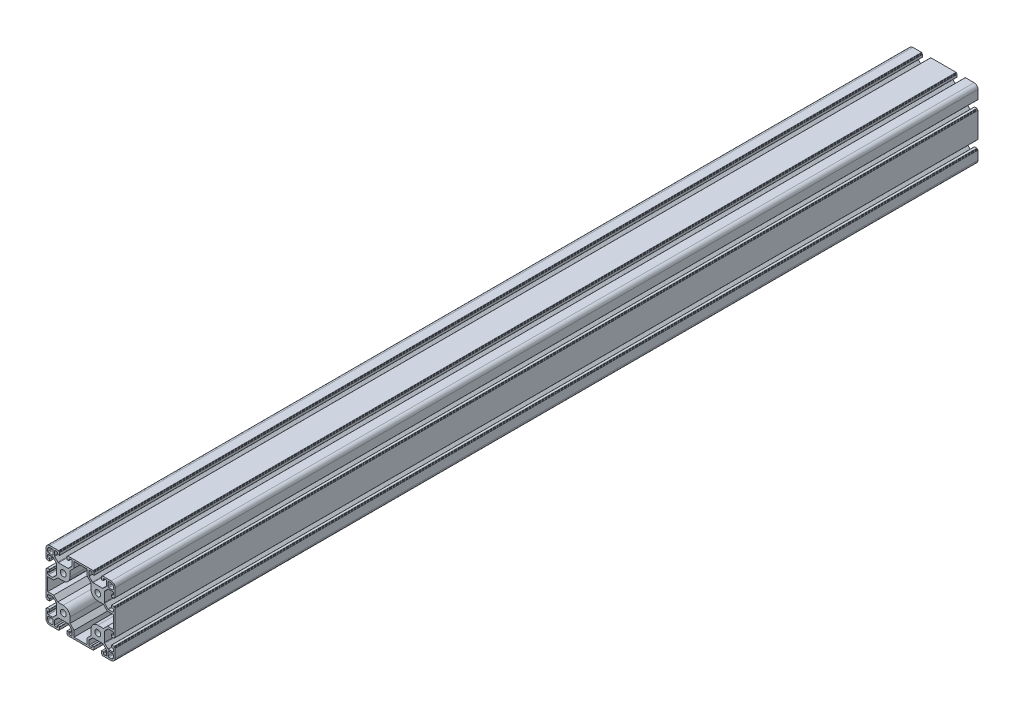
from build123d import *

# Parameters (mm, degrees)
SKETCH_1_R      = 3.4
EXTRUDE_1_DEPTH = 1000


with BuildPart() as part:
    # Эскиз1 → Бобышка-Вытянуть1 (new body)
    with BuildSketch(Plane.XY):
        with BuildLine():
            Line((-20, 10.25), (-20, 15.5))
            ThreePointArc((-20, 15.5), (-18.681980515, 18.681980515), (-15.5, 20))
            Line((-15.5, 20), (-10.25, 20))
            Line((-10.25, 20), (-5.4, 20))
            ThreePointArc((-5.4, 20), (-5.187867966, 19.912132034), (-5.1, 19.7))
            Line((-5.1, 19.7), (-5.1, 19.3))
            ThreePointArc((-5.1, 19.3), (-5.012132034, 19.087867966), (-4.8, 19))
            Line((-4.8, 19), (-4.4, 19))
            ThreePointArc((-4.4, 19), (-4.187867966, 18.912132034), (-4.1, 18.7))
            Line((-4.1, 18.7), (-4.1, 16))
            ThreePointArc((-4.1, 16), (-4.187867966, 15.787867966), (-4.4, 15.7))
            Line((-4.4, 15.7), (-6.3, 15.7))
            ThreePointArc((-6.3, 15.7), (-6.512132034, 15.787867966), (-6.6, 16))
            Line((-6.6, 16), (-6.6, 17.2))
            ThreePointArc((-6.6, 17.2), (-6.892893219, 17.907106781), (-7.6, 18.2))
            Line((-7.6, 18.2), (-9.25, 18.2))
            ThreePointArc((-9.25, 18.2), (-9.957106781, 17.907106781), (-10.25, 17.2))
            Line((-10.25, 17.2), (-10.25, 12.464213562))
            ThreePointArc((-10.25, 12.464213562), (-10.173879533, 12.08153013), (-9.957106781, 11.757106781))
            Line((-9.957106781, 11.757106781), (-6.192893219, 7.992893219))
            ThreePointArc((-6.192893219, 7.992893219), (-5.86846987, 7.776120467), (-5.485786438, 7.7))
            Line((-5.485786438, 7.7), (5.485786438, 7.7))
            ThreePointArc((5.485786438, 7.7), (5.86846987, 7.776120467), (6.192893219, 7.992893219))
            Line((6.192893219, 7.992893219), (9.957106781, 11.757106781))
            ThreePointArc((9.957106781, 11.757106781), (10.173879533, 12.08153013), (10.25, 12.464213562))
            Line((10.25, 12.464213562), (10.25, 17.2))
            ThreePointArc((10.25, 17.2), (9.957106781, 17.907106781), (9.25, 18.2))
            Line((9.25, 18.2), (7.6, 18.2))
            ThreePointArc((7.6, 18.2), (6.892893219, 17.907106781), (6.6, 17.2))
            Line((6.6, 17.2), (6.6, 16))
            ThreePointArc((6.6, 16), (6.512132034, 15.787867966), (6.3, 15.7))
            Line((6.3, 15.7), (4.4, 15.7))
            ThreePointArc((4.4, 15.7), (4.187867966, 15.787867966), (4.1, 16))
            Line((4.1, 16), (4.1, 18.7))
            ThreePointArc((4.1, 18.7), (4.187867966, 18.912132034), (4.4, 19))
            Line((4.4, 19), (4.8, 19))
            ThreePointArc((4.8, 19), (5.012132034, 19.087867966), (5.1, 19.3))
            Line((5.1, 19.3), (5.1, 19.7))
            ThreePointArc((5.1, 19.7), (5.187867966, 19.912132034), (5.4, 20))
            Line((5.4, 20), (10.25, 20))
            Line((10.25, 20), (29.75, 20))
            Line((29.75, 20), (34.6, 20))
            ThreePointArc((34.6, 20), (34.812132034, 19.912132034), (34.9, 19.7))
            Line((34.9, 19.7), (34.9, 19.3))
            ThreePointArc((34.9, 19.3), (34.987867966, 19.087867966), (35.2, 19))
            Line((35.2, 19), (35.6, 19))
            ThreePointArc((35.6, 19), (35.812132034, 18.912132034), (35.9, 18.7))
            Line((35.9, 18.7), (35.9, 16))
            ThreePointArc((35.9, 16), (35.812132034, 15.787867966), (35.6, 15.7))
            Line((35.6, 15.7), (33.7, 15.7))
            ThreePointArc((33.7, 15.7), (33.487867966, 15.787867966), (33.4, 16))
            Line((33.4, 16), (33.4, 17.2))
            ThreePointArc((33.4, 17.2), (33.107106781, 17.907106781), (32.4, 18.2))
            Line((32.4, 18.2), (30.75, 18.2))
            ThreePointArc((30.75, 18.2), (30.042893219, 17.907106781), (29.75, 17.2))
            Line((29.75, 17.2), (29.75, 12.464213562))
            ThreePointArc((29.75, 12.464213562), (29.826120467, 12.08153013), (30.042893219, 11.757106781))
            Line((30.042893219, 11.757106781), (33.807106781, 7.992893219))
            ThreePointArc((33.807106781, 7.992893219), (34.13153013, 7.776120467), (34.514213562, 7.7))
            Line((34.514213562, 7.7), (45.485786438, 7.7))
            ThreePointArc((45.485786438, 7.7), (45.86846987, 7.776120467), (46.192893219, 7.992893219))
            Line((46.192893219, 7.992893219), (49.957106781, 11.757106781))
            ThreePointArc((49.957106781, 11.757106781), (50.173879533, 12.08153013), (50.25, 12.464213562))
            Line((50.25, 12.464213562), (50.25, 17.2))
            ThreePointArc((50.25, 17.2), (49.957106781, 17.907106781), (49.25, 18.2))
            Line((49.25, 18.2), (47.6, 18.2))
            ThreePointArc((47.6, 18.2), (46.892893219, 17.907106781), (46.6, 17.2))
            Line((46.6, 17.2), (46.6, 16))
            ThreePointArc((46.6, 16), (46.512132034, 15.787867966), (46.3, 15.7))
            Line((46.3, 15.7), (44.4, 15.7))
            ThreePointArc((44.4, 15.7), (44.187867966, 15.787867966), (44.1, 16))
            Line((44.1, 16), (44.1, 18.7))
            ThreePointArc((44.1, 18.7), (44.187867966, 18.912132034), (44.4, 19))
            Line((44.4, 19), (44.8, 19))
            ThreePointArc((44.8, 19), (45.012132034, 19.087867966), (45.1, 19.3))
            Line((45.1, 19.3), (45.1, 19.7))
            ThreePointArc((45.1, 19.7), (45.187867966, 19.912132034), (45.4, 20))
            Line((45.4, 20), (50.25, 20))
            Line((50.25, 20), (55.5, 20))
            ThreePointArc((55.5, 20), (58.681980515, 18.681980515), (60, 15.5))
            Line((60, 15.5), (60, 10.25))
            Line((60, 10.25), (60, 5.4))
            ThreePointArc((60, 5.4), (59.912132034, 5.187867966), (59.7, 5.1))
            Line((59.7, 5.1), (59.3, 5.1))
            ThreePointArc((59.3, 5.1), (59.087867966, 5.012132034), (59, 4.8))
            Line((59, 4.8), (59, 4.4))
            ThreePointArc((59, 4.4), (58.912132034, 4.187867966), (58.7, 4.1))
            Line((58.7, 4.1), (56, 4.1))
            ThreePointArc((56, 4.1), (55.787867966, 4.187867966), (55.7, 4.4))
            Line((55.7, 4.4), (55.7, 6.3))
            ThreePointArc((55.7, 6.3), (55.787867966, 6.512132034), (56, 6.6))
            Line((56, 6.6), (57.2, 6.6))
            ThreePointArc((57.2, 6.6), (57.907106781, 6.892893219), (58.2, 7.6))
            Line((58.2, 7.6), (58.2, 9.25))
            ThreePointArc((58.2, 9.25), (57.907106781, 9.957106781), (57.2, 10.25))
            Line((57.2, 10.25), (52.464213562, 10.25))
            ThreePointArc((52.464213562, 10.25), (52.08153013, 10.173879533), (51.757106781, 9.957106781))
            Line((51.757106781, 9.957106781), (47.992893219, 6.192893219))
            ThreePointArc((47.992893219, 6.192893219), (47.776120467, 5.86846987), (47.7, 5.485786438))
            Line((47.7, 5.485786438), (47.7, -5.485786438))
            ThreePointArc((47.7, -5.485786438), (47.776120467, -5.86846987), (47.992893219, -6.192893219))
            Line((47.992893219, -6.192893219), (51.757106781, -9.957106781))
            ThreePointArc((51.757106781, -9.957106781), (52.08153013, -10.173879533), (52.464213562, -10.25))
            Line((52.464213562, -10.25), (57.2, -10.25))
            ThreePointArc((57.2, -10.25), (57.907106781, -9.957106781), (58.2, -9.25))
            Line((58.2, -9.25), (58.2, -7.6))
            ThreePointArc((58.2, -7.6), (57.907106781, -6.892893219), (57.2, -6.6))
            Line((57.2, -6.6), (56, -6.6))
            ThreePointArc((56, -6.6), (55.787867966, -6.512132034), (55.7, -6.3))
            Line((55.7, -6.3), (55.7, -4.4))
            ThreePointArc((55.7, -4.4), (55.787867966, -4.187867966), (56, -4.1))
            Line((56, -4.1), (58.7, -4.1))
            ThreePointArc((58.7, -4.1), (58.912132034, -4.187867966), (59, -4.4))
            Line((59, -4.4), (59, -4.8))
            ThreePointArc((59, -4.8), (59.087867966, -5.012132034), (59.3, -5.1))
            Line((59.3, -5.1), (59.7, -5.1))
            ThreePointArc((59.7, -5.1), (59.912132034, -5.187867966), (60, -5.4))
            Line((60, -5.4), (60, -10.25))
            Line((60, -10.25), (60, -29.75))
            Line((60, -29.75), (60, -34.6))
            ThreePointArc((60, -34.6), (59.912132034, -34.812132034), (59.7, -34.9))
            Line((59.7, -34.9), (59.3, -34.9))
            ThreePointArc((59.3, -34.9), (59.087867966, -34.987867966), (59, -35.2))
            Line((59, -35.2), (59, -35.6))
            ThreePointArc((59, -35.6), (58.912132034, -35.812132034), (58.7, -35.9))
            Line((58.7, -35.9), (56, -35.9))
            ThreePointArc((56, -35.9), (55.787867966, -35.812132034), (55.7, -35.6))
            Line((55.7, -35.6), (55.7, -33.7))
            ThreePointArc((55.7, -33.7), (55.787867966, -33.487867966), (56, -33.4))
            Line((56, -33.4), (57.2, -33.4))
            ThreePointArc((57.2, -33.4), (57.907106781, -33.107106781), (58.2, -32.4))
            Line((58.2, -32.4), (58.2, -30.75))
            ThreePointArc((58.2, -30.75), (57.907106781, -30.042893219), (57.2, -29.75))
            Line((57.2, -29.75), (52.464213562, -29.75))
            ThreePointArc((52.464213562, -29.75), (52.08153013, -29.826120467), (51.757106781, -30.042893219))
            Line((51.757106781, -30.042893219), (47.992893219, -33.807106781))
            ThreePointArc((47.992893219, -33.807106781), (47.776120467, -34.13153013), (47.7, -34.514213562))
            Line((47.7, -34.514213562), (47.7, -45.485786438))
            ThreePointArc((47.7, -45.485786438), (47.776120467, -45.86846987), (47.992893219, -46.192893219))
            Line((47.992893219, -46.192893219), (51.757106781, -49.957106781))
            ThreePointArc((51.757106781, -49.957106781), (52.08153013, -50.173879533), (52.464213562, -50.25))
            Line((52.464213562, -50.25), (57.2, -50.25))
            ThreePointArc((57.2, -50.25), (57.907106781, -49.957106781), (58.2, -49.25))
            Line((58.2, -49.25), (58.2, -47.6))
            ThreePointArc((58.2, -47.6), (57.907106781, -46.892893219), (57.2, -46.6))
            Line((57.2, -46.6), (56, -46.6))
            ThreePointArc((56, -46.6), (55.787867966, -46.512132034), (55.7, -46.3))
            Line((55.7, -46.3), (55.7, -44.4))
            ThreePointArc((55.7, -44.4), (55.787867966, -44.187867966), (56, -44.1))
            Line((56, -44.1), (58.7, -44.1))
            ThreePointArc((58.7, -44.1), (58.912132034, -44.187867966), (59, -44.4))
            Line((59, -44.4), (59, -44.8))
            ThreePointArc((59, -44.8), (59.087867966, -45.012132034), (59.3, -45.1))
            Line((59.3, -45.1), (59.7, -45.1))
            ThreePointArc((59.7, -45.1), (59.912132034, -45.187867966), (60, -45.4))
            Line((60, -45.4), (60, -50.25))
            Line((60, -50.25), (60, -55.5))
            ThreePointArc((60, -55.5), (58.681980515, -58.681980515), (55.5, -60))
            Line((55.5, -60), (50.25, -60))
            Line((50.25, -60), (45.4, -60))
            ThreePointArc((45.4, -60), (45.187867966, -59.912132034), (45.1, -59.7))
            Line((45.1, -59.7), (45.1, -59.3))
            ThreePointArc((45.1, -59.3), (45.012132034, -59.087867966), (44.8, -59))
            Line((44.8, -59), (44.4, -59))
            ThreePointArc((44.4, -59), (44.187867966, -58.912132034), (44.1, -58.7))
            Line((44.1, -58.7), (44.1, -56))
            ThreePointArc((44.1, -56), (44.187867966, -55.787867966), (44.4, -55.7))
            Line((44.4, -55.7), (46.3, -55.7))
            ThreePointArc((46.3, -55.7), (46.512132034, -55.787867966), (46.6, -56))
            Line((46.6, -56), (46.6, -57.2))
            ThreePointArc((46.6, -57.2), (46.892893219, -57.907106781), (47.6, -58.2))
            Line((47.6, -58.2), (49.25, -58.2))
            ThreePointArc((49.25, -58.2), (49.957106781, -57.907106781), (50.25, -57.2))
            Line((50.25, -57.2), (50.25, -52.464213562))
            ThreePointArc((50.25, -52.464213562), (50.173879533, -52.08153013), (49.957106781, -51.757106781))
            Line((49.957106781, -51.757106781), (46.192893219, -47.992893219))
            ThreePointArc((46.192893219, -47.992893219), (45.86846987, -47.776120467), (45.485786438, -47.7))
            Line((45.485786438, -47.7), (34.514213562, -47.7))
            ThreePointArc((34.514213562, -47.7), (34.13153013, -47.776120467), (33.807106781, -47.992893219))
            Line((33.807106781, -47.992893219), (30.042893219, -51.757106781))
            ThreePointArc((30.042893219, -51.757106781), (29.826120467, -52.08153013), (29.75, -52.464213562))
            Line((29.75, -52.464213562), (29.75, -57.2))
            ThreePointArc((29.75, -57.2), (30.042893219, -57.907106781), (30.75, -58.2))
            Line((30.75, -58.2), (32.4, -58.2))
            ThreePointArc((32.4, -58.2), (33.107106781, -57.907106781), (33.4, -57.2))
            Line((33.4, -57.2), (33.4, -56))
            ThreePointArc((33.4, -56), (33.487867966, -55.787867966), (33.7, -55.7))
            Line((33.7, -55.7), (35.6, -55.7))
            ThreePointArc((35.6, -55.7), (35.812132034, -55.787867966), (35.9, -56))
            Line((35.9, -56), (35.9, -58.7))
            ThreePointArc((35.9, -58.7), (35.812132034, -58.912132034), (35.6, -59))
            Line((35.6, -59), (35.2, -59))
            ThreePointArc((35.2, -59), (34.987867966, -59.087867966), (34.9, -59.3))
            Line((34.9, -59.3), (34.9, -59.7))
            ThreePointArc((34.9, -59.7), (34.812132034, -59.912132034), (34.6, -60))
            Line((34.6, -60), (29.75, -60))
            Line((29.75, -60), (10.25, -60))
            Line((10.25, -60), (5.4, -60))
            ThreePointArc((5.4, -60), (5.187867966, -59.912132034), (5.1, -59.7))
            Line((5.1, -59.7), (5.1, -59.3))
            ThreePointArc((5.1, -59.3), (5.012132034, -59.087867966), (4.8, -59))
            Line((4.8, -59), (4.4, -59))
            ThreePointArc((4.4, -59), (4.187867966, -58.912132034), (4.1, -58.7))
            Line((4.1, -58.7), (4.1, -56))
            ThreePointArc((4.1, -56), (4.187867966, -55.787867966), (4.4, -55.7))
            Line((4.4, -55.7), (6.3, -55.7))
            ThreePointArc((6.3, -55.7), (6.512132034, -55.787867966), (6.6, -56))
            Line((6.6, -56), (6.6, -57.2))
            ThreePointArc((6.6, -57.2), (6.892893219, -57.907106781), (7.6, -58.2))
            Line((7.6, -58.2), (9.25, -58.2))
            ThreePointArc((9.25, -58.2), (9.957106781, -57.907106781), (10.25, -57.2))
            Line((10.25, -57.2), (10.25, -52.464213562))
            ThreePointArc((10.25, -52.464213562), (10.173879533, -52.08153013), (9.957106781, -51.757106781))
            Line((9.957106781, -51.757106781), (6.192893219, -47.992893219))
            ThreePointArc((6.192893219, -47.992893219), (5.86846987, -47.776120467), (5.485786438, -47.7))
            Line((5.485786438, -47.7), (-5.485786438, -47.7))
            ThreePointArc((-5.485786438, -47.7), (-5.86846987, -47.776120467), (-6.192893219, -47.992893219))
            Line((-6.192893219, -47.992893219), (-9.957106781, -51.757106781))
            ThreePointArc((-9.957106781, -51.757106781), (-10.173879533, -52.08153013), (-10.25, -52.464213562))
            Line((-10.25, -52.464213562), (-10.25, -57.2))
            ThreePointArc((-10.25, -57.2), (-9.957106781, -57.907106781), (-9.25, -58.2))
            Line((-9.25, -58.2), (-7.6, -58.2))
            ThreePointArc((-7.6, -58.2), (-6.892893219, -57.907106781), (-6.6, -57.2))
            Line((-6.6, -57.2), (-6.6, -56))
            ThreePointArc((-6.6, -56), (-6.512132034, -55.787867966), (-6.3, -55.7))
            Line((-6.3, -55.7), (-4.4, -55.7))
            ThreePointArc((-4.4, -55.7), (-4.187867966, -55.787867966), (-4.1, -56))
            Line((-4.1, -56), (-4.1, -58.7))
            ThreePointArc((-4.1, -58.7), (-4.187867966, -58.912132034), (-4.4, -59))
            Line((-4.4, -59), (-4.8, -59))
            ThreePointArc((-4.8, -59), (-5.012132034, -59.087867966), (-5.1, -59.3))
            Line((-5.1, -59.3), (-5.1, -59.7))
            ThreePointArc((-5.1, -59.7), (-5.187867966, -59.912132034), (-5.4, -60))
            Line((-5.4, -60), (-10.25, -60))
            Line((-10.25, -60), (-15.5, -60))
            ThreePointArc((-15.5, -60), (-18.681980515, -58.681980515), (-20, -55.5))
            Line((-20, -55.5), (-20, -50.25))
            Line((-20, -50.25), (-20, -45.4))
            ThreePointArc((-20, -45.4), (-19.912132034, -45.187867966), (-19.7, -45.1))
            Line((-19.7, -45.1), (-19.3, -45.1))
            ThreePointArc((-19.3, -45.1), (-19.087867966, -45.012132034), (-19, -44.8))
            Line((-19, -44.8), (-19, -44.4))
            ThreePointArc((-19, -44.4), (-18.912132034, -44.187867966), (-18.7, -44.1))
            Line((-18.7, -44.1), (-16, -44.1))
            ThreePointArc((-16, -44.1), (-15.787867966, -44.187867966), (-15.7, -44.4))
            Line((-15.7, -44.4), (-15.7, -46.3))
            ThreePointArc((-15.7, -46.3), (-15.787867966, -46.512132034), (-16, -46.6))
            Line((-16, -46.6), (-17.2, -46.6))
            ThreePointArc((-17.2, -46.6), (-17.907106781, -46.892893219), (-18.2, -47.6))
            Line((-18.2, -47.6), (-18.2, -49.25))
            ThreePointArc((-18.2, -49.25), (-17.907106781, -49.957106781), (-17.2, -50.25))
            Line((-17.2, -50.25), (-12.464213562, -50.25))
            ThreePointArc((-12.464213562, -50.25), (-12.08153013, -50.173879533), (-11.757106781, -49.957106781))
            Line((-11.757106781, -49.957106781), (-7.992893219, -46.192893219))
            ThreePointArc((-7.992893219, -46.192893219), (-7.776120467, -45.86846987), (-7.7, -45.485786438))
            Line((-7.7, -45.485786438), (-7.7, -34.514213562))
            ThreePointArc((-7.7, -34.514213562), (-7.776120467, -34.13153013), (-7.992893219, -33.807106781))
            Line((-7.992893219, -33.807106781), (-11.757106781, -30.042893219))
            ThreePointArc((-11.757106781, -30.042893219), (-12.08153013, -29.826120467), (-12.464213562, -29.75))
            Line((-12.464213562, -29.75), (-17.2, -29.75))
            ThreePointArc((-17.2, -29.75), (-17.907106781, -30.042893219), (-18.2, -30.75))
            Line((-18.2, -30.75), (-18.2, -32.4))
            ThreePointArc((-18.2, -32.4), (-17.907106781, -33.107106781), (-17.2, -33.4))
            Line((-17.2, -33.4), (-16, -33.4))
            ThreePointArc((-16, -33.4), (-15.787867966, -33.487867966), (-15.7, -33.7))
            Line((-15.7, -33.7), (-15.7, -35.6))
            ThreePointArc((-15.7, -35.6), (-15.787867966, -35.812132034), (-16, -35.9))
            Line((-16, -35.9), (-18.7, -35.9))
            ThreePointArc((-18.7, -35.9), (-18.912132034, -35.812132034), (-19, -35.6))
            Line((-19, -35.6), (-19, -35.2))
            ThreePointArc((-19, -35.2), (-19.087867966, -34.987867966), (-19.3, -34.9))
            Line((-19.3, -34.9), (-19.7, -34.9))
            ThreePointArc((-19.7, -34.9), (-19.912132034, -34.812132034), (-20, -34.6))
            Line((-20, -34.6), (-20, -29.75))
            Line((-20, -29.75), (-20, -10.25))
            Line((-20, -10.25), (-20, -5.4))
            ThreePointArc((-20, -5.4), (-19.912132034, -5.187867966), (-19.7, -5.1))
            Line((-19.7, -5.1), (-19.3, -5.1))
            ThreePointArc((-19.3, -5.1), (-19.087867966, -5.012132034), (-19, -4.8))
            Line((-19, -4.8), (-19, -4.4))
            ThreePointArc((-19, -4.4), (-18.912132034, -4.187867966), (-18.7, -4.1))
            Line((-18.7, -4.1), (-16, -4.1))
            ThreePointArc((-16, -4.1), (-15.787867966, -4.187867966), (-15.7, -4.4))
            Line((-15.7, -4.4), (-15.7, -6.3))
            ThreePointArc((-15.7, -6.3), (-15.787867966, -6.512132034), (-16, -6.6))
            Line((-16, -6.6), (-17.2, -6.6))
            ThreePointArc((-17.2, -6.6), (-17.907106781, -6.892893219), (-18.2, -7.6))
            Line((-18.2, -7.6), (-18.2, -9.25))
            ThreePointArc((-18.2, -9.25), (-17.907106781, -9.957106781), (-17.2, -10.25))
            Line((-17.2, -10.25), (-12.464213562, -10.25))
            ThreePointArc((-12.464213562, -10.25), (-12.08153013, -10.173879533), (-11.757106781, -9.957106781))
            Line((-11.757106781, -9.957106781), (-7.992893219, -6.192893219))
            ThreePointArc((-7.992893219, -6.192893219), (-7.776120467, -5.86846987), (-7.7, -5.485786438))
            Line((-7.7, -5.485786438), (-7.7, 5.485786438))
            ThreePointArc((-7.7, 5.485786438), (-7.776120467, 5.86846987), (-7.992893219, 6.192893219))
            Line((-7.992893219, 6.192893219), (-11.757106781, 9.957106781))
            ThreePointArc((-11.757106781, 9.957106781), (-12.08153013, 10.173879533), (-12.464213562, 10.25))
            Line((-12.464213562, 10.25), (-17.2, 10.25))
            ThreePointArc((-17.2, 10.25), (-17.907106781, 9.957106781), (-18.2, 9.25))
            Line((-18.2, 9.25), (-18.2, 7.6))
            ThreePointArc((-18.2, 7.6), (-17.907106781, 6.892893219), (-17.2, 6.6))
            Line((-17.2, 6.6), (-16, 6.6))
            ThreePointArc((-16, 6.6), (-15.787867966, 6.512132034), (-15.7, 6.3))
            Line((-15.7, 6.3), (-15.7, 4.4))
            ThreePointArc((-15.7, 4.4), (-15.787867966, 4.187867966), (-16, 4.1))
            Line((-16, 4.1), (-18.7, 4.1))
            ThreePointArc((-18.7, 4.1), (-18.912132034, 4.187867966), (-19, 4.4))
            Line((-19, 4.4), (-19, 4.8))
            ThreePointArc((-19, 4.8), (-19.087867966, 5.012132034), (-19.3, 5.1))
            Line((-19.3, 5.1), (-19.7, 5.1))
            ThreePointArc((-19.7, 5.1), (-19.912132034, 5.187867966), (-20, 5.4))
            Line((-20, 5.4), (-20, 10.25))
        make_face()
        Circle(SKETCH_1_R, mode=Mode.SUBTRACT)
        with Locations((40, 0)):
            Circle(SKETCH_1_R, mode=Mode.SUBTRACT)
        with Locations((40, -40)):
            Circle(SKETCH_1_R, mode=Mode.SUBTRACT)
        with Locations((0, -40)):
            Circle(SKETCH_1_R, mode=Mode.SUBTRACT)
        with BuildLine():
            Line((-12.8, 11.8), (-17, 11.8))
            ThreePointArc((-17, 11.8), (-17.707106781, 12.092893219), (-18, 12.8))
            Line((-18, 12.8), (-18, 15.5))
            ThreePointArc((-18, 15.5), (-17.267766953, 17.267766953), (-15.5, 18))
            Line((-15.5, 18), (-12.8, 18))
            ThreePointArc((-12.8, 18), (-12.092893219, 17.707106781), (-11.8, 17))
            Line((-11.8, 17), (-11.8, 12.8))
            ThreePointArc((-11.8, 12.8), (-12.092893219, 12.092893219), (-12.8, 11.8))
        make_face(mode=Mode.SUBTRACT)
        with BuildLine():
            Line((51.8, 12.8), (51.8, 17))
            ThreePointArc((51.8, 17), (52.092893219, 17.707106781), (52.8, 18))
            Line((52.8, 18), (55.5, 18))
            ThreePointArc((55.5, 18), (57.267766953, 17.267766953), (58, 15.5))
            Line((58, 15.5), (58, 12.8))
            ThreePointArc((58, 12.8), (57.707106781, 12.092893219), (57, 11.8))
            Line((57, 11.8), (52.8, 11.8))
            ThreePointArc((52.8, 11.8), (52.092893219, 12.092893219), (51.8, 12.8))
        make_face(mode=Mode.SUBTRACT)
        with BuildLine():
            Line((52.8, -51.8), (57, -51.8))
            ThreePointArc((57, -51.8), (57.707106781, -52.092893219), (58, -52.8))
            Line((58, -52.8), (58, -55.5))
            ThreePointArc((58, -55.5), (57.267766953, -57.267766953), (55.5, -58))
            Line((55.5, -58), (52.8, -58))
            ThreePointArc((52.8, -58), (52.092893219, -57.707106781), (51.8, -57))
            Line((51.8, -57), (51.8, -52.8))
            ThreePointArc((51.8, -52.8), (52.092893219, -52.092893219), (52.8, -51.8))
        make_face(mode=Mode.SUBTRACT)
        with BuildLine():
            Line((-11.8, -52.8), (-11.8, -57))
            ThreePointArc((-11.8, -57), (-12.092893219, -57.707106781), (-12.8, -58))
            Line((-12.8, -58), (-15.5, -58))
            ThreePointArc((-15.5, -58), (-17.267766953, -57.267766953), (-18, -55.5))
            Line((-18, -55.5), (-18, -52.8))
            ThreePointArc((-18, -52.8), (-17.707106781, -52.092893219), (-17, -51.8))
            Line((-17, -51.8), (-12.8, -51.8))
            ThreePointArc((-12.8, -51.8), (-12.092893219, -52.092893219), (-11.8, -52.8))
        make_face(mode=Mode.SUBTRACT)
        with BuildLine():
            Line((-18, -27.55), (-18, -12.45))
            Line((-18, -12.45), (-11.138730163, -12.45))
            Line((-11.138730163, -12.45), (-6.488730163, -7.8))
            Line((-6.488730163, -7.8), (0, -7.8))
            ThreePointArc((0, -7.8), (5.515432893, -5.515432893), (7.8, 0))
            Line((7.8, 0), (7.8, 6.488730163))
            Line((7.8, 6.488730163), (12.45, 11.138730163))
            Line((12.45, 11.138730163), (12.45, 18))
            Line((12.45, 18), (27.55, 18))
            Line((27.55, 18), (27.55, 11.138730163))
            Line((27.55, 11.138730163), (32.2, 6.488730163))
            Line((32.2, 6.488730163), (32.2, 0))
            ThreePointArc((32.2, 0), (34.484567107, -5.515432893), (40, -7.8))
            Line((40, -7.8), (46.488730163, -7.8))
            Line((46.488730163, -7.8), (51.138730163, -12.45))
            Line((51.138730163, -12.45), (58, -12.45))
            Line((58, -12.45), (58, -27.55))
            Line((58, -27.55), (51.138730163, -27.55))
            Line((51.138730163, -27.55), (46.488730163, -32.2))
            Line((46.488730163, -32.2), (40, -32.2))
            ThreePointArc((40, -32.2), (34.484567107, -34.484567107), (32.2, -40))
            Line((32.2, -40), (32.2, -46.488730163))
            Line((32.2, -46.488730163), (27.55, -51.138730163))
            Line((27.55, -51.138730163), (27.55, -58))
            Line((27.55, -58), (12.45, -58))
            Line((12.45, -58), (12.45, -51.138730163))
            Line((12.45, -51.138730163), (7.8, -46.488730163))
            Line((7.8, -46.488730163), (7.8, -40))
            ThreePointArc((7.8, -40), (5.515432893, -34.484567107), (0, -32.2))
            Line((0, -32.2), (-6.488730163, -32.2))
            Line((-6.488730163, -32.2), (-11.138730163, -27.55))
            Line((-11.138730163, -27.55), (-18, -27.55))
        make_face(mode=Mode.SUBTRACT)
    extrude(amount=EXTRUDE_1_DEPTH)


solid = part.part
